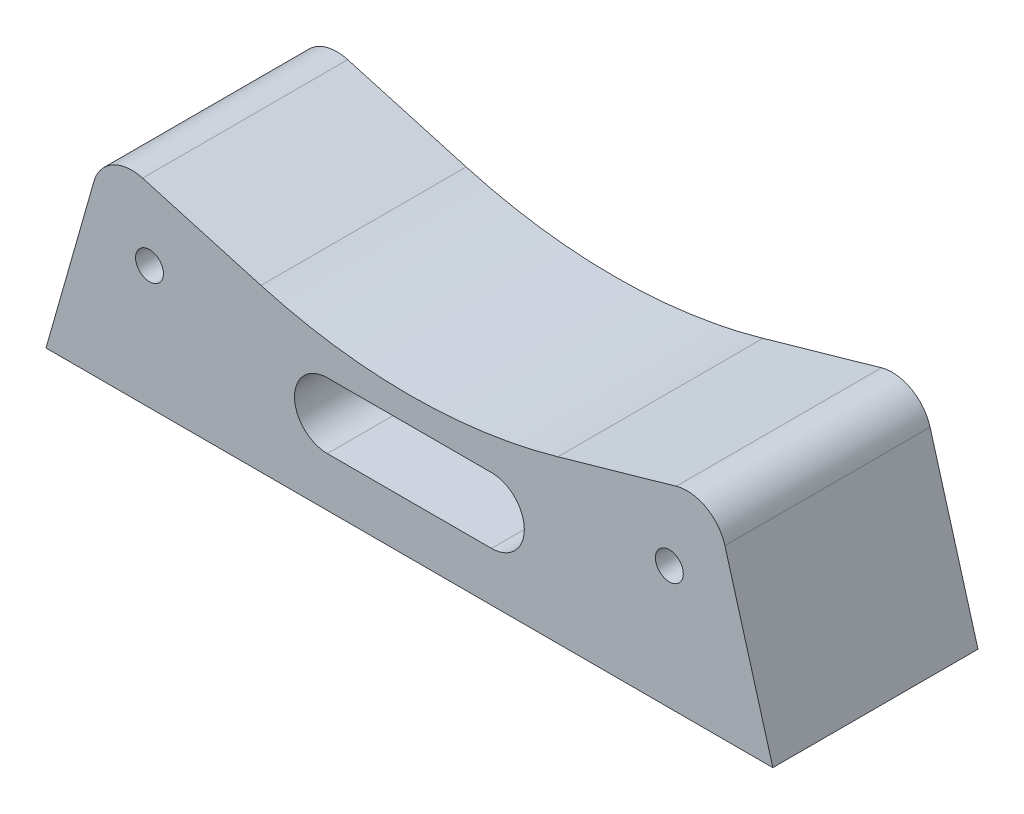
from build123d import *

# Parameters (mm, degrees)
BOSS_EXTRU_1_DEPTH      = 25
ENL_V_MAT_EXTRU_1_DEPTH = 26
ESQUISSE13_R            = 1.7
ENL_V_MAT_EXTRU_2_DEPTH = 29


with BuildPart() as part:
    # Esquisse1 → Boss.-Extru.1 (new body)
    with BuildSketch(Plane.XY.offset(25)):
        with BuildLine():
            Line((18.085571367, -30.291755058), (32.51257447, -26.185469451))
            ThreePointArc((32.51257447, -26.185469451), (36.161897649, -26.608505924), (38.443226857, -29.48809905))
            Line((38.443226857, -29.48809905), (44.28142645, -50))
            Line((44.28142645, -50), (-44.28142645, -50))
            Line((-44.28142645, -50), (-38.443226857, -29.48809905))
            ThreePointArc((-38.443226857, -29.48809905), (-36.161897649, -26.608505924), (-32.51257447, -26.185469451))
            Line((-32.51257447, -26.185469451), (-18.085571367, -30.291755058))
            ThreePointArc((-18.085571367, -30.291755058), (-9.130400918, -32.181477949), (0, -32.81544125))
            ThreePointArc((0, -32.81544125), (9.130400918, -32.181477949), (18.085571367, -30.291755058))
        make_face()
    extrude(amount=-BOSS_EXTRU_1_DEPTH)

    # Esquisse2 → Enlèv. mat.-Extru.1 (cut, through all)
    with BuildSketch(Plane(origin=(0, 0, 0), x_dir=(-1, 0, 0), z_dir=(0, 0, -1))):
        with BuildLine():
            Line((-10, -44), (10, -44))
            ThreePointArc((10, -44), (14, -40), (10, -36))
            Line((10, -36), (-10, -36))
            ThreePointArc((-10, -36), (-14, -40), (-10, -44))
        make_face()
    extrude(amount=-ENL_V_MAT_EXTRU_1_DEPTH, mode=Mode.SUBTRACT)

    # Esquisse13 → Enlèv. mat.-Extru.2 (cut, through all)
    with BuildSketch(Plane(origin=(0, 0, -3), x_dir=(-1, 0, 0), z_dir=(0, 0, -1))):
        with Locations((31.669980911, -35)):
            Circle(ESQUISSE13_R)
        with Locations((-31.669980911, -35)):
            Circle(ESQUISSE13_R)
    extrude(amount=-ENL_V_MAT_EXTRU_2_DEPTH, mode=Mode.SUBTRACT)


solid = part.part
